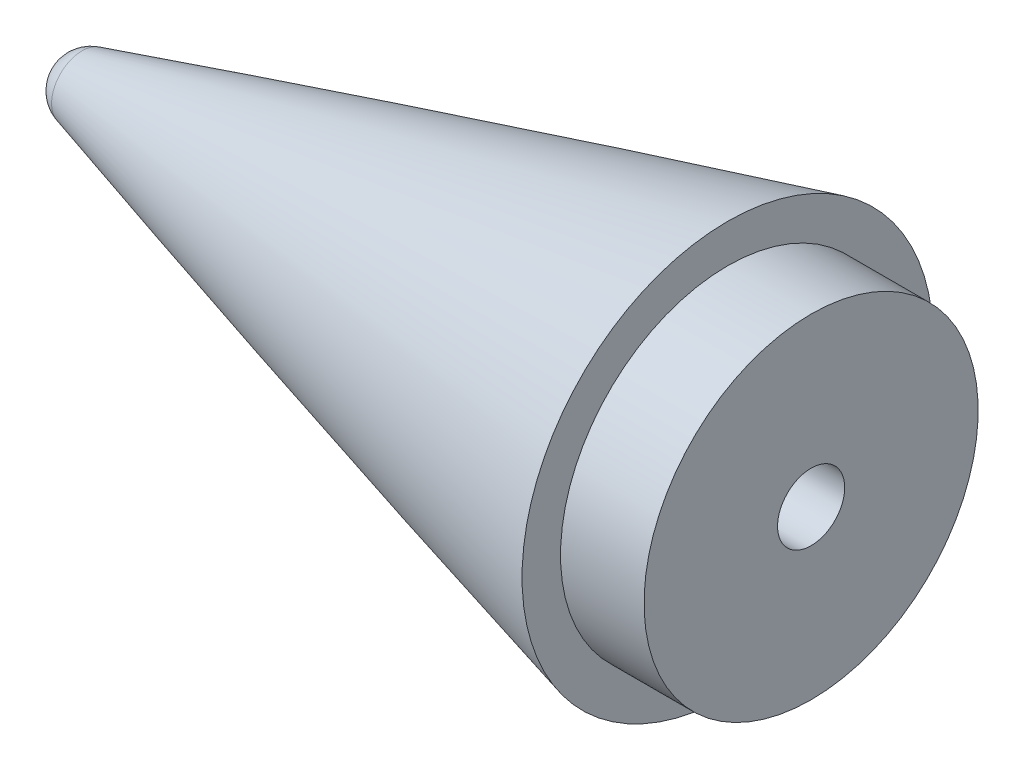
from build123d import *

# Parameters (mm, degrees)
SKETCH2_R                       = 12.7
BOSS_EXTRUDE1_DEPTH             = 6.35
TAP_DRILL_FOR_1_4_20_TAP1_D     = 5.1054
TAP_DRILL_FOR_1_4_20_TAP1_DEPTH = 25.4
TAP_DRILL_FOR_1_4_20_TAP1_TIP   = 1.533816902


with BuildPart() as part:
    # Sketch1 → Revolve2 (revolve)
    with BuildSketch(Plane.XY):
        with BuildLine():
            Line((-596.9, 0), (-647.721869411, 0))
            ThreePointArc((-647.721869411, 0), (-647.234752146, 1.453803526), (-645.970071075, 2.320642445))
            ThreePointArc((-645.970071075, 2.320642445), (-621.477598816, 9.129959938), (-596.9, 15.625315086))
            Line((-596.9, 15.625315086), (-596.9, 0))
        make_face()
    revolve(axis=Axis((0, 0, 0), (-1, 0, 0)))

    # Sketch2 → Boss-Extrude1 (add)
    with BuildSketch(Plane(origin=(-596.9, 0, 0), x_dir=(0, 0, -1), z_dir=(1, 0, 0))):
        Circle(SKETCH2_R)
    extrude(amount=BOSS_EXTRUDE1_DEPTH)

    # Tap Drill for 1/4-20 Tap1
    with Locations(Plane(origin=(-590.55, 0, 0), x_dir=(0, 0, -1), z_dir=(1, 0, 0))):
        with Locations((0, 0)):
            Hole(TAP_DRILL_FOR_1_4_20_TAP1_D / 2, depth=TAP_DRILL_FOR_1_4_20_TAP1_DEPTH)
            with Locations((0, 0, -(TAP_DRILL_FOR_1_4_20_TAP1_DEPTH + TAP_DRILL_FOR_1_4_20_TAP1_TIP / 2))):  # 118° drill point
                Cone(0, TAP_DRILL_FOR_1_4_20_TAP1_D / 2, TAP_DRILL_FOR_1_4_20_TAP1_TIP, mode=Mode.SUBTRACT)


solid = part.part
